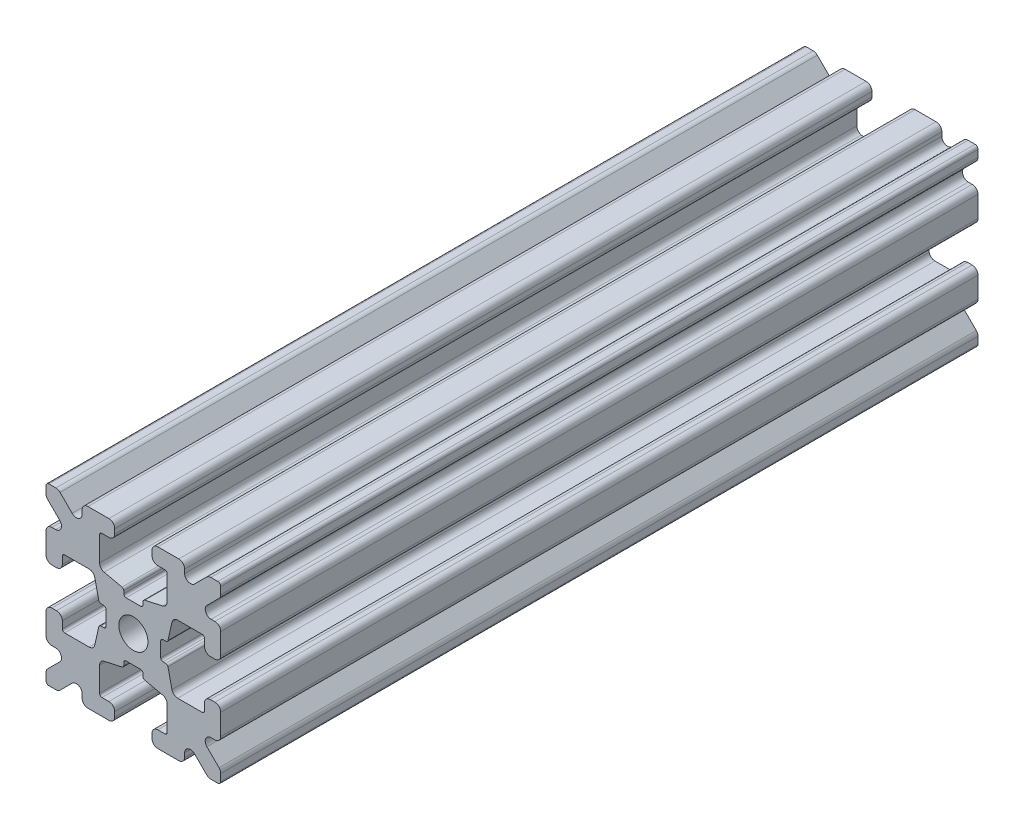
from build123d import *

# Parameters (mm, degrees)
SKETCH1_W           = 15
SKETCH1_H           = 15
SKETCH1_R           = 1.25
BOSS_EXTRUDE1_DEPTH = 32.5
FILLET1_R           = 0.25
CUT_EXTRUDE1_DEPTH  = 66
CUT_EXTRUDE3_DEPTH  = 66
FILLET3_R           = 0.5
FILLET4_R           = 0.5
FILLET5_R           = 3
FILLET6_R           = 0.2
CUT_EXTRUDE4_DEPTH  = 66
FILLET8_R           = 0.5
SKETCH6_W           = 5.1529354
SKETCH6_H           = 1.651
SKETCH6_W_2         = 1.651
SKETCH6_H_2         = 5.1529354
CUT_EXTRUDE5_DEPTH  = 66
FILLET10_R          = 0.2


with BuildPart() as part:
    # Sketch1 → Boss-Extrude1 (new body, symmetric)
    with BuildSketch(Plane.XY):
        Rectangle(SKETCH1_W, SKETCH1_H)
        Circle(SKETCH1_R, mode=Mode.SUBTRACT)
    extrude(amount=BOSS_EXTRUDE1_DEPTH, both=True)

    # Fillet1
    fillet1_edges = [part.edges().sort_by_distance(p)[0] for p in [
        (7.5, -7.5, 0),
        (-7.5, -7.5, 0),
        (-7.5, 7.5, 0),
        (7.5, 7.5, 0),
    ]]
    fillet(fillet1_edges, radius=FILLET1_R)

    # Sketch2 → Cut-Extrude1 (cut, through all)
    with BuildSketch(Plane.XY.offset(32.5)):
        Polygon((-7.5, 1.6), (-6.1, 1.6), (-6.1, 2.9), (-3.4, 2.9), (-3.4, -2.9), (-6.1, -2.9), (-6.1, -1.6), (-7.5, -1.6), align=None)
        Polygon((2.9, 6.1), (1.6, 6.1), (1.6, 7.5), (-1.6, 7.5), (-1.6, 6.1), (-2.9, 6.1), (-2.9, 3.4), (2.9, 3.4), align=None)
        Polygon((-1.6, -7.5), (-1.6, -6.1), (-2.9, -6.1), (-2.9, -3.4), (2.9, -3.4), (2.9, -6.1), (1.6, -6.1), (1.6, -7.5), align=None)
        Polygon((6.1, -2.9), (6.1, -1.6), (7.5, -1.6), (7.5, 1.6), (6.1, 1.6), (6.1, 2.9), (3.4, 2.9), (3.4, -2.9), align=None)
    extrude(amount=-CUT_EXTRUDE1_DEPTH, mode=Mode.SUBTRACT)

    # Sketch4 → Cut-Extrude3 (cut, through all)
    with BuildSketch(Plane.XY.offset(32.5)):
        Polygon((-3.4, 2.9), (-2.75, 0), (-3.4, -2.9), align=None)
        Polygon((-2.9, 3.4), (0, 2.75), (2.9, 3.4), align=None)
        Polygon((3.4, 2.9), (2.75, 0), (3.4, -2.9), align=None)
        Polygon((-2.9, -3.4), (0, -2.75), (2.9, -3.4), align=None)
    extrude(amount=-CUT_EXTRUDE3_DEPTH, mode=Mode.SUBTRACT)

    # Fillet3
    fillet3_edges = [part.edges().sort_by_distance(p)[0] for p in [
        (1.6, -7.5, 0),
        (-1.6, -7.5, 0),
        (-1.6, -6.1, 0),
        (1.6, -6.1, 0),
        (6.1, 1.6, 0),
        (7.5, 1.6, 0),
        (7.5, -1.6, 0),
        (6.1, -1.6, 0),
        (-7.5, -1.6, 0),
        (-7.5, 1.6, 0),
        (-6.1, 1.6, 0),
        (-6.1, -1.6, 0),
        (-1.6, 6.1, 0),
        (-1.6, 7.5, 0),
        (1.6, 7.5, 0),
        (1.6, 6.1, 0),
    ]]
    fillet(fillet3_edges, radius=FILLET3_R)

    # Fillet4
    fillet4_edges = [part.edges().sort_by_distance(p)[0] for p in [
        (-2.9, -3.4, 0),
        (2.9, -3.4, 0),
        (3.4, -2.9, 0),
        (3.4, 2.9, 0),
        (-3.4, 2.9, 0),
        (-3.4, -2.9, 0),
        (2.9, 3.4, 0),
        (-2.9, 3.4, 0),
    ]]
    fillet(fillet4_edges, radius=FILLET4_R)

    # Fillet5
    fillet5_edges = [part.edges().sort_by_distance(p)[0] for p in [
        (-2.75, 0, 0),
        (0, 2.75, 0),
        (2.75, 0, 0),
        (0, -2.75, 0),
    ]]
    fillet(fillet5_edges, radius=FILLET5_R)

    # Fillet6
    fillet6_edges = [part.edges().sort_by_distance(p)[0] for p in [
        (-2.9, -6.1, 0),
        (2.9, -6.1, 0),
        (6.1, -2.9, 0),
        (6.1, 2.9, 0),
        (-6.1, 2.9, 0),
        (-6.1, -2.9, 0),
        (2.9, 6.1, 0),
        (-2.9, 6.1, 0),
    ]]
    fillet(fillet6_edges, radius=FILLET6_R)

    # Sketch5 → Cut-Extrude4 (cut, through all)
    with BuildSketch(Plane.XY.offset(32.5)):
        Polygon((-7.5, 6.439339828), (-5.460660172, 4.4), (-7.5, 4.4), align=None)
        Polygon((-6.439339828, 7.5), (-4.4, 5.460660172), (-4.4, 7.5), align=None)
        Polygon((4.4, 7.5), (6.439339828, 7.5), (4.4, 5.460660172), align=None)
        Polygon((7.5, 6.439339828), (7.5, 4.4), (5.460660172, 4.4), align=None)
        Polygon((7.5, -6.439339828), (5.460660172, -4.4), (7.5, -4.4), align=None)
        Polygon((6.439339828, -7.5), (4.4, -5.460660172), (4.4, -7.5), align=None)
        Polygon((-4.4, -7.5), (-6.439339828, -7.5), (-4.4, -5.460660172), align=None)
        Polygon((-7.5, -6.439339828), (-7.5, -4.4), (-5.460660172, -4.4), align=None)
    extrude(amount=-CUT_EXTRUDE4_DEPTH, mode=Mode.SUBTRACT)

    # Fillet8
    fillet8_edges = [part.edges().sort_by_distance(p)[0] for p in [
        (-7.5, 4.4, 0),
        (-7.5, 6.439339828, 0),
        (-5.460660172, 4.4, 0),
        (7.5, -4.4, 0),
        (7.5, -6.439339828, 0),
        (5.460660172, -4.4, 0),
        (5.460660172, 4.4, 0),
        (7.5, 6.439339828, 0),
        (7.5, 4.4, 0),
        (-4.4, 7.5, 0),
        (-4.4, 5.460660172, 0),
        (-6.439339828, 7.5, 0),
        (-5.460660172, -4.4, 0),
        (-7.5, -6.439339828, 0),
        (-7.5, -4.4, 0),
        (4.4, 5.460660172, 0),
        (4.4, 7.5, 0),
        (6.439339828, 7.5, 0),
        (6.439339828, -7.5, 0),
        (4.4, -7.5, 0),
        (4.4, -5.460660172, 0),
        (-6.439339828, -7.5, 0),
        (-4.4, -5.460660172, 0),
        (-4.4, -7.5, 0),
    ]]
    fillet(fillet8_edges, radius=FILLET8_R)

    # Sketch6 → Cut-Extrude5 (cut, through all)
    with BuildSketch(Plane.XY.offset(32.5)):
        with Locations((4.9235323, 0)):
            Rectangle(SKETCH6_W, SKETCH6_H)
        with Locations((0, -4.9235323)):
            Rectangle(SKETCH6_W_2, SKETCH6_H_2)
        with Locations((-4.9235323, 0)):
            Rectangle(SKETCH6_W, SKETCH6_H)
        with Locations((0, 4.9235323)):
            Rectangle(SKETCH6_W_2, SKETCH6_H_2)
    extrude(amount=-CUT_EXTRUDE5_DEPTH, mode=Mode.SUBTRACT)

    # Fillet10
    fillet10_edges = [part.edges().sort_by_distance(p)[0] for p in [
        (0.8255, -2.935025862, 0),
        (-0.8255, -2.935025862, 0),
        (0.8255, -2.3470646, 0),
        (-0.8255, -2.3470646, 0),
        (2.935025862, 0.8255, 0),
        (2.935025862, -0.8255, 0),
        (2.3470646, 0.8255, 0),
        (2.3470646, -0.8255, 0),
        (-2.935025862, -0.8255, 0),
        (-2.935025862, 0.8255, 0),
        (-2.3470646, -0.8255, 0),
        (-2.3470646, 0.8255, 0),
        (-0.8255, 2.935025862, 0),
        (0.8255, 2.935025862, 0),
        (-0.8255, 2.3470646, 0),
        (0.8255, 2.3470646, 0),
    ]]
    fillet(fillet10_edges, radius=FILLET10_R)


solid = part.part
